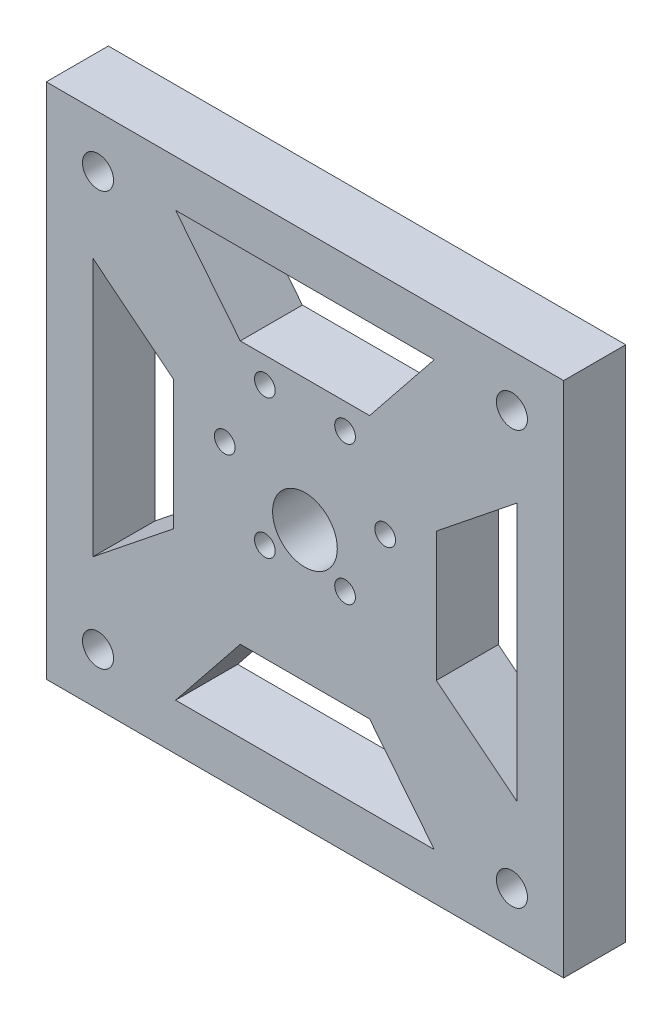
from build123d import *

# Parameters (mm, degrees)
ESQUISSE1_R             = 18.5
BOSS_EXTRU_1_DEPTH      = 12
ESQUISSE2_R             = 2
ENL_V_MAT_EXTRU_1_DEPTH = 13
ESQUISSE3_R             = 6.25
ENL_V_MAT_EXTRU_2_DEPTH = 13
ESQUISSE4_W             = 100
ESQUISSE4_H             = 100
ESQUISSE4_R             = 18.5
BOSS_EXTRU_2_DEPTH      = 12
ESQUISSE5_R             = 3
ENL_V_MAT_EXTRU_3_DEPTH = 12
ENL_V_MAT_EXTRU_4_DEPTH = 12


with BuildPart() as part:
    # Esquisse1 → Boss.-Extru.1 (new body)
    with BuildSketch(Plane.XY):
        Circle(ESQUISSE1_R)
    extrude(amount=BOSS_EXTRU_1_DEPTH)

    # Esquisse2 → Enlèv. mat.-Extru.1 (cut, through all)
    with BuildSketch(Plane.XY.offset(12)):
        with Locations((15.5, 0)):
            Circle(ESQUISSE2_R)
        with Locations((7.75, -13.423393759)):
            Circle(ESQUISSE2_R)
        with Locations((-7.75, -13.423393759)):
            Circle(ESQUISSE2_R)
        with Locations((-15.5, 0)):
            Circle(ESQUISSE2_R)
        with Locations((-7.75, 13.423393759)):
            Circle(ESQUISSE2_R)
        with Locations((7.75, 13.423393759)):
            Circle(ESQUISSE2_R)
    extrude(amount=-ENL_V_MAT_EXTRU_1_DEPTH, mode=Mode.SUBTRACT)

    # Esquisse3 → Enlèv. mat.-Extru.2 (cut, through all)
    with BuildSketch(Plane.XY.offset(12)):
        with Locations((0, -7)):
            Circle(ESQUISSE3_R)
    extrude(amount=-ENL_V_MAT_EXTRU_2_DEPTH, mode=Mode.SUBTRACT)

    # Esquisse4 → Boss.-Extru.2 (add)
    with BuildSketch(Plane.XY.offset(12)):
        with Locations((0, -7)):
            Rectangle(ESQUISSE4_W, ESQUISSE4_H)
        Circle(ESQUISSE4_R, mode=Mode.SUBTRACT)
    extrude(amount=-BOSS_EXTRU_2_DEPTH)

    # Esquisse5 → Enlèv. mat.-Extru.3 (cut)
    with BuildSketch(Plane.XY.offset(12)):
        with Locations((-40, 33)):
            Circle(ESQUISSE5_R)
        with Locations((40, 33)):
            Circle(ESQUISSE5_R)
        with Locations((40, -47)):
            Circle(ESQUISSE5_R)
        with Locations((-40, -47)):
            Circle(ESQUISSE5_R)
    extrude(amount=-ENL_V_MAT_EXTRU_3_DEPTH, mode=Mode.SUBTRACT)

    # Esquisse6 → Enlèv. mat.-Extru.4 (cut)
    with BuildSketch(Plane.XY.offset(12)):
        Polygon((-41, 18), (-41, -32), (-25.387505004, -19.5), (-25.387505004, 5.5), align=None)
        Polygon((12.5, 18.387505004), (25, 34), (-25, 34), (-12.5, 18.387505004), align=None)
        Polygon((25.387505004, -19.5), (41, -32), (41, 18), (25.387505004, 5.5), align=None)
        Polygon((-12.5, -32.387505004), (-25, -48), (25, -48), (12.5, -32.387505004), align=None)
    extrude(amount=-ENL_V_MAT_EXTRU_4_DEPTH, mode=Mode.SUBTRACT)


solid = part.part
